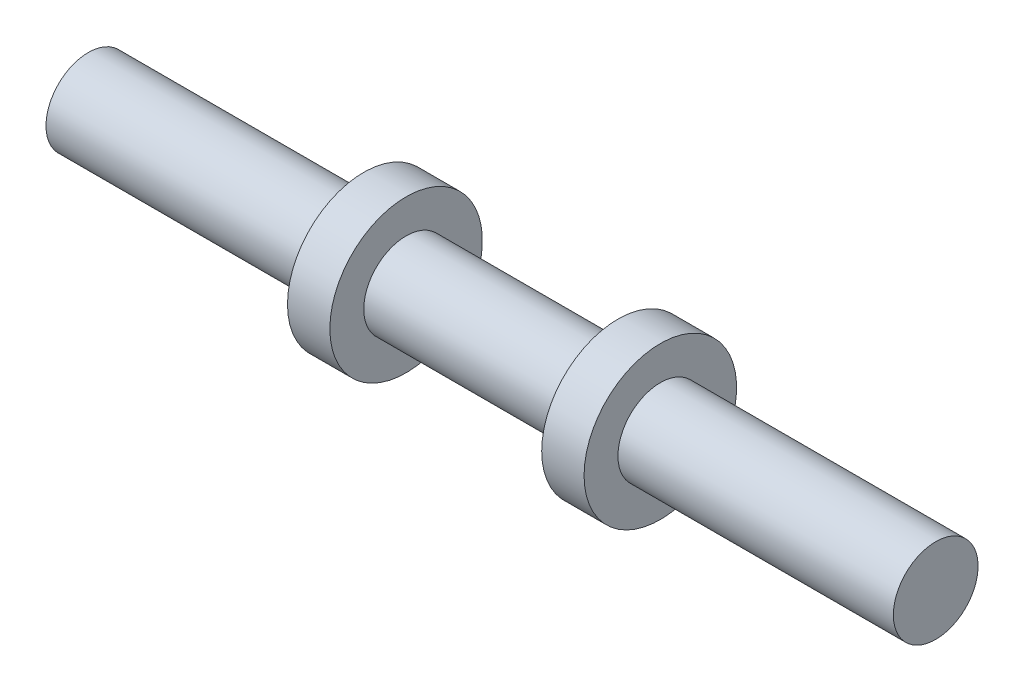
from build123d import *

# Parameters (mm, degrees)
SKETCH1_R            = 1.8
BOSS_EXTRUDE1_DEPTH  = 20
CUT_EXTRUDE1_DEPTH   = 6.5
CUT_EXTRUDE2_DEPTH   = 5
MIRROR2_COPY_1_DEPTH = 6.5


with BuildPart() as part:
    # Sketch1 → Boss-Extrude1 (new body)
    with BuildSketch(Plane(origin=(0, 0, 0), x_dir=(0, 0, -1), z_dir=(1, 0, 0))):
        Circle(SKETCH1_R)
    extrude(amount=BOSS_EXTRUDE1_DEPTH)

    # Sketch2 → Cut-Extrude1 (cut)
    with BuildSketch(Plane(origin=(20, 0, 0), x_dir=(0, 0, -1), z_dir=(1, 0, 0))):
        with BuildLine():
            Line((-1, 0), (-1.8, 0))
            ThreePointArc((-1.8, 0), (0, 1.8), (1.8, 0))
            Line((1.8, 0), (1, 0))
            ThreePointArc((1, 0), (0, 1), (-1, 0))
        make_face()
    cut_extrude1 = extrude(amount=-CUT_EXTRUDE1_DEPTH, mode=Mode.SUBTRACT)

    # Sketch3 → Cut-Extrude2 (cut)
    with BuildSketch(Plane(origin=(12.5, 0, 0), x_dir=(0, 0, -1), z_dir=(1, 0, 0))):
        with BuildLine():
            Line((-1, 0), (-1.8, 0))
            ThreePointArc((-1.8, 0), (0, 1.8), (1.8, 0))
            Line((1.8, 0), (1, 0))
            ThreePointArc((1, 0), (0, 1), (-1, 0))
        make_face()
    cut_extrude2 = extrude(amount=-CUT_EXTRUDE2_DEPTH, mode=Mode.SUBTRACT)

    # Mirror1: Cut-Extrude1 across plane
    add(cut_extrude1.mirror(Plane(origin=(10, 0, 0), x_dir=(0, 0, 1), z_dir=(1, 0, 0))), mode=Mode.SUBTRACT)

    # Mirror2: Cut-Extrude2, Cut-Extrude1 across plane
    add(cut_extrude2.mirror(Plane.ZX), mode=Mode.SUBTRACT)
    add(cut_extrude1.mirror(Plane.ZX), mode=Mode.SUBTRACT)

    # Mirror2 copy 1 sketch → Mirror2 copy 1 (cut)
    with BuildSketch(Plane(origin=(0, 0, 0), x_dir=(0, 0, -1), z_dir=(-1, 0, 0))):
        with BuildLine():
            Line((-1, 0), (-1.8, 0))
            ThreePointArc((-1.8, 0), (0, 1.8), (1.8, 0))
            Line((1.8, 0), (1, 0))
            ThreePointArc((1, 0), (0, 1), (-1, 0))
        make_face()
    extrude(amount=-MIRROR2_COPY_1_DEPTH, mode=Mode.SUBTRACT)


solid = part.part
